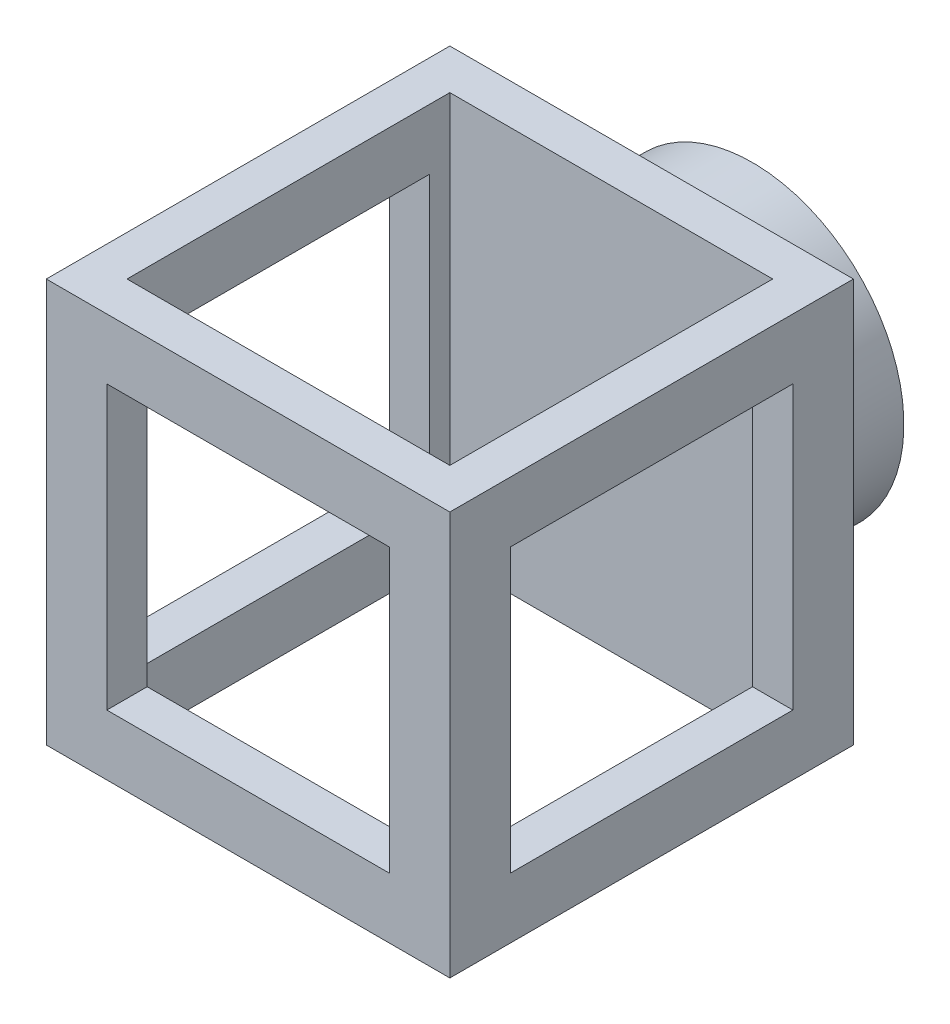
from build123d import *

# Parameters (mm, degrees)
SKETCH1_W           = 20
SKETCH1_H           = 20
SKETCH1_W_2         = 16
SKETCH1_H_2         = 16
BOSS_EXTRUDE1_DEPTH = 10
SKETCH2_W           = 14
SKETCH2_H           = 14
CUT_EXTRUDE1_DEPTH  = 21
SKETCH3_W           = 14
SKETCH3_H           = 14
CUT_EXTRUDE2_DEPTH  = 21
SKETCH4_W           = 2
SKETCH4_H           = 14
BOSS_EXTRUDE2_DEPTH = 14
SKETCH5_R           = 7.5
BOSS_EXTRUDE3_DEPTH = 5


with BuildPart() as part:
    # Sketch1 → Boss-Extrude1 (new body, symmetric)
    with BuildSketch(Plane(origin=(0, 0, 0), x_dir=(1, 0, 0), z_dir=(0, 1, 0))):
        Rectangle(SKETCH1_W, SKETCH1_H)
        Rectangle(SKETCH1_W_2, SKETCH1_H_2, mode=Mode.SUBTRACT)
    extrude(amount=BOSS_EXTRUDE1_DEPTH, both=True)

    # Sketch2 → Cut-Extrude1 (cut, through all)
    with BuildSketch(Plane.XY.offset(10)):
        Rectangle(SKETCH2_W, SKETCH2_H)
    extrude(amount=-CUT_EXTRUDE1_DEPTH, mode=Mode.SUBTRACT)

    # Sketch3 → Cut-Extrude2 (cut, through all)
    with BuildSketch(Plane(origin=(10, 0, 0), x_dir=(0, 0, -1), z_dir=(1, 0, 0))):
        Rectangle(SKETCH3_W, SKETCH3_H)
    extrude(amount=-CUT_EXTRUDE2_DEPTH, mode=Mode.SUBTRACT)

    # Sketch4 → Boss-Extrude2 (add)
    with BuildSketch(Plane(origin=(-7, 0, 0), x_dir=(0, 0, -1), z_dir=(1, 0, 0))):
        with Locations((9, 0)):
            Rectangle(SKETCH4_W, SKETCH4_H)
    extrude(amount=BOSS_EXTRUDE2_DEPTH)

    # Sketch5 → Boss-Extrude3 (add)
    with BuildSketch(Plane(origin=(0, 0, -10), x_dir=(-1, 0, 0), z_dir=(0, 0, -1))):
        Circle(SKETCH5_R)
    extrude(amount=BOSS_EXTRUDE3_DEPTH)


solid = part.part
